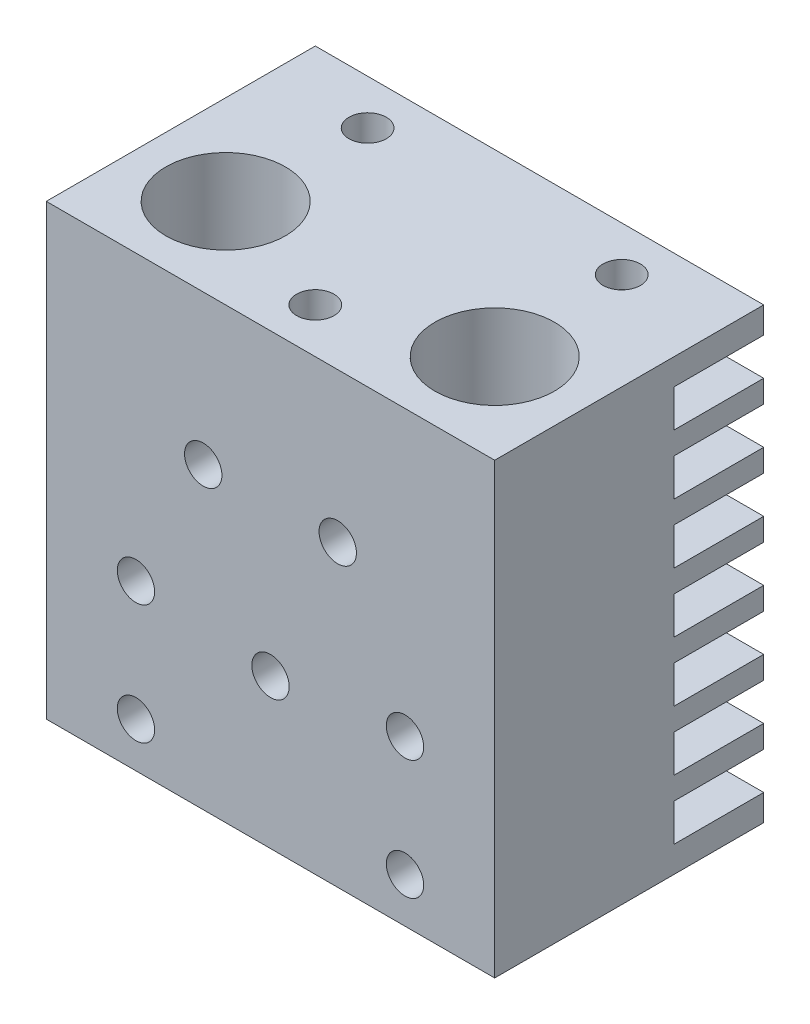
from build123d import *

# Parameters (mm, degrees)
SKETCH1_W             = 30
SKETCH1_H             = 18
BOSS_EXTRUDE1_DEPTH   = 30
SKETCH2_R             = 1.25
CUT_EXTRUDE1_DEPTH    = 8
SKETCH3_R             = 4
CUT_EXTRUDE2_DEPTH    = 6.5
SKETCH4_R             = 2.1
CUT_EXTRUDE3_DEPTH    = 24.5
CUT_EXTRUDE4_REACH    = 32
SKETCH5_W             = 12
SKETCH5_H             = 2.5
SKETCH6_R             = 3.45
CUT_EXTRUDE5_DEPTH    = 14
SKETCH7_R             = 1.25
CUT_EXTRUDE6_DEPTH    = 19
CHAMFER1_SIZE         = 1.7
CHAMFER1_SIZE2        = 0.65256886
CHAMFER1_PART_2_SIZE  = 1.7
CHAMFER1_PART_2_SIZE2 = 0.65256886


with BuildPart() as part:
    # Sketch1 → Boss-Extrude1 (new body)
    with BuildSketch(Plane(origin=(0, 0, 0), x_dir=(1, 0, 0), z_dir=(0, 1, 0))):
        Rectangle(SKETCH1_W, SKETCH1_H)
    extrude(amount=BOSS_EXTRUDE1_DEPTH)

    # Sketch2 → Cut-Extrude1 (cut)
    with BuildSketch(Plane(origin=(0, 30, 0), x_dir=(1, 0, 0), z_dir=(0, 1, 0))):
        with Locations((0, -6)):
            Circle(SKETCH2_R)
        with Locations((-8.5, 6)):
            Circle(SKETCH2_R)
        with Locations((8.5, 6)):
            Circle(SKETCH2_R)
    extrude(amount=-CUT_EXTRUDE1_DEPTH, mode=Mode.SUBTRACT)

    # Sketch3 → Cut-Extrude2 (cut)
    with BuildSketch(Plane(origin=(0, 30, 0), x_dir=(1, 0, 0), z_dir=(0, 1, 0))):
        with Locations((-9, -3)):
            Circle(SKETCH3_R)
        with Locations((9, -3)):
            Circle(SKETCH3_R)
    extrude(amount=-CUT_EXTRUDE2_DEPTH, mode=Mode.SUBTRACT)

    # Sketch4 → Cut-Extrude3 (cut, through all)
    with BuildSketch(Plane(origin=(0, 23.5, 0), x_dir=(1, 0, 0), z_dir=(0, 1, 0))):
        with Locations((9, -3)):
            Circle(SKETCH4_R)
        with Locations((-9, -3)):
            Circle(SKETCH4_R)
    extrude(amount=-CUT_EXTRUDE3_DEPTH, mode=Mode.SUBTRACT)

    # Sketch5 → Cut-Extrude4 (cut, up to next)
    with BuildSketch(Plane(origin=(15, 0, 0), x_dir=(0, 0, -1), z_dir=(1, 0, 0)), mode=Mode.PRIVATE) as cut_extrude4_sk1:
        with Locations((9, 7)):
            Rectangle(SKETCH5_W, SKETCH5_H)
    cut_extrude4_tool1 = extrude(cut_extrude4_sk1.sketch, amount=-CUT_EXTRUDE4_REACH, mode=Mode.PRIVATE) & part.part
    add(cut_extrude4_tool1.solids().sort_by_distance((15, 7, -9))[0], mode=Mode.SUBTRACT)
    # Sketch5 → Cut-Extrude4 (cut, up to next)
    with BuildSketch(Plane(origin=(15, 0, 0), x_dir=(0, 0, -1), z_dir=(1, 0, 0)), mode=Mode.PRIVATE) as cut_extrude4_sk2:
        with Locations((9, 11)):
            Rectangle(SKETCH5_W, SKETCH5_H)
    cut_extrude4_tool2 = extrude(cut_extrude4_sk2.sketch, amount=-CUT_EXTRUDE4_REACH, mode=Mode.PRIVATE) & part.part
    add(cut_extrude4_tool2.solids().sort_by_distance((15, 11, -9))[0], mode=Mode.SUBTRACT)
    # Sketch5 → Cut-Extrude4 (cut, up to next)
    with BuildSketch(Plane(origin=(15, 0, 0), x_dir=(0, 0, -1), z_dir=(1, 0, 0)), mode=Mode.PRIVATE) as cut_extrude4_sk3:
        with Locations((9, 15)):
            Rectangle(SKETCH5_W, SKETCH5_H)
    cut_extrude4_tool3 = extrude(cut_extrude4_sk3.sketch, amount=-CUT_EXTRUDE4_REACH, mode=Mode.PRIVATE) & part.part
    add(cut_extrude4_tool3.solids().sort_by_distance((15, 15, -9))[0], mode=Mode.SUBTRACT)
    # Sketch5 → Cut-Extrude4 (cut, up to next)
    with BuildSketch(Plane(origin=(15, 0, 0), x_dir=(0, 0, -1), z_dir=(1, 0, 0)), mode=Mode.PRIVATE) as cut_extrude4_sk4:
        with Locations((9, 19)):
            Rectangle(SKETCH5_W, SKETCH5_H)
    cut_extrude4_tool4 = extrude(cut_extrude4_sk4.sketch, amount=-CUT_EXTRUDE4_REACH, mode=Mode.PRIVATE) & part.part
    add(cut_extrude4_tool4.solids().sort_by_distance((15, 19, -9))[0], mode=Mode.SUBTRACT)
    # Sketch5 → Cut-Extrude4 (cut, up to next)
    with BuildSketch(Plane(origin=(15, 0, 0), x_dir=(0, 0, -1), z_dir=(1, 0, 0)), mode=Mode.PRIVATE) as cut_extrude4_sk5:
        with Locations((9, 23)):
            Rectangle(SKETCH5_W, SKETCH5_H)
    cut_extrude4_tool5 = extrude(cut_extrude4_sk5.sketch, amount=-CUT_EXTRUDE4_REACH, mode=Mode.PRIVATE) & part.part
    add(cut_extrude4_tool5.solids().sort_by_distance((15, 23, -9))[0], mode=Mode.SUBTRACT)
    # Sketch5 → Cut-Extrude4 (cut, up to next)
    with BuildSketch(Plane(origin=(15, 0, 0), x_dir=(0, 0, -1), z_dir=(1, 0, 0)), mode=Mode.PRIVATE) as cut_extrude4_sk6:
        with Locations((9, 27)):
            Rectangle(SKETCH5_W, SKETCH5_H)
    cut_extrude4_tool6 = extrude(cut_extrude4_sk6.sketch, amount=-CUT_EXTRUDE4_REACH, mode=Mode.PRIVATE) & part.part
    add(cut_extrude4_tool6.solids().sort_by_distance((15, 27, -9))[0], mode=Mode.SUBTRACT)
    # Sketch5 → Cut-Extrude4 (cut, up to next)
    with BuildSketch(Plane(origin=(15, 0, 0), x_dir=(0, 0, -1), z_dir=(1, 0, 0)), mode=Mode.PRIVATE) as cut_extrude4_sk7:
        with Locations((9, 3)):
            Rectangle(SKETCH5_W, SKETCH5_H)
    cut_extrude4_tool7 = extrude(cut_extrude4_sk7.sketch, amount=-CUT_EXTRUDE4_REACH, mode=Mode.PRIVATE) & part.part
    add(cut_extrude4_tool7.solids().sort_by_distance((15, 3, -9))[0], mode=Mode.SUBTRACT)

    # Sketch6 → Cut-Extrude5 (cut)
    with BuildSketch(Plane.XZ):
        with Locations((9, 3)):
            Circle(SKETCH6_R)
        with Locations((-9, 3)):
            Circle(SKETCH6_R)
    extrude(amount=-CUT_EXTRUDE5_DEPTH, mode=Mode.SUBTRACT)

    # Sketch7 → Cut-Extrude6 (cut, through all)
    with BuildSketch(Plane.XY.offset(9)):
        with Locations((-4.5, 20)):
            Circle(SKETCH7_R)
        with Locations((4.5, 20)):
            Circle(SKETCH7_R)
        with Locations((-9, 11)):
            Circle(SKETCH7_R)
        with Locations((-9, 3)):
            Circle(SKETCH7_R)
        with Locations((9, 11)):
            Circle(SKETCH7_R)
        with Locations((9, 3)):
            Circle(SKETCH7_R)
        with Locations((0, 10)):
            Circle(SKETCH7_R)
    extrude(amount=-CUT_EXTRUDE6_DEPTH, mode=Mode.SUBTRACT)

    # Chamfer1
    chamfer1_edges = [part.edges().sort_by_distance(p)[0] for p in [
        (6.9, 23.5, 3),
    ]]
    chamfer1_side = [part.faces().sort_by_distance(p)[0] for p in [
        (5.113137085, 23.5, 3),
    ]]
    chamfer(chamfer1_edges, length=CHAMFER1_SIZE, length2=CHAMFER1_SIZE2, reference=chamfer1_side[0])

    # Chamfer1 part 2
    chamfer1_part_2_edges = [part.edges().sort_by_distance(p)[0] for p in [
        (-11.1, 23.5, 3),
    ]]
    chamfer1_part_2_side = [part.faces().sort_by_distance(p)[0] for p in [
        (-12.886862915, 23.5, 3),
    ]]
    chamfer(chamfer1_part_2_edges, length=CHAMFER1_PART_2_SIZE, length2=CHAMFER1_PART_2_SIZE2, reference=chamfer1_part_2_side[0])


solid = part.part
